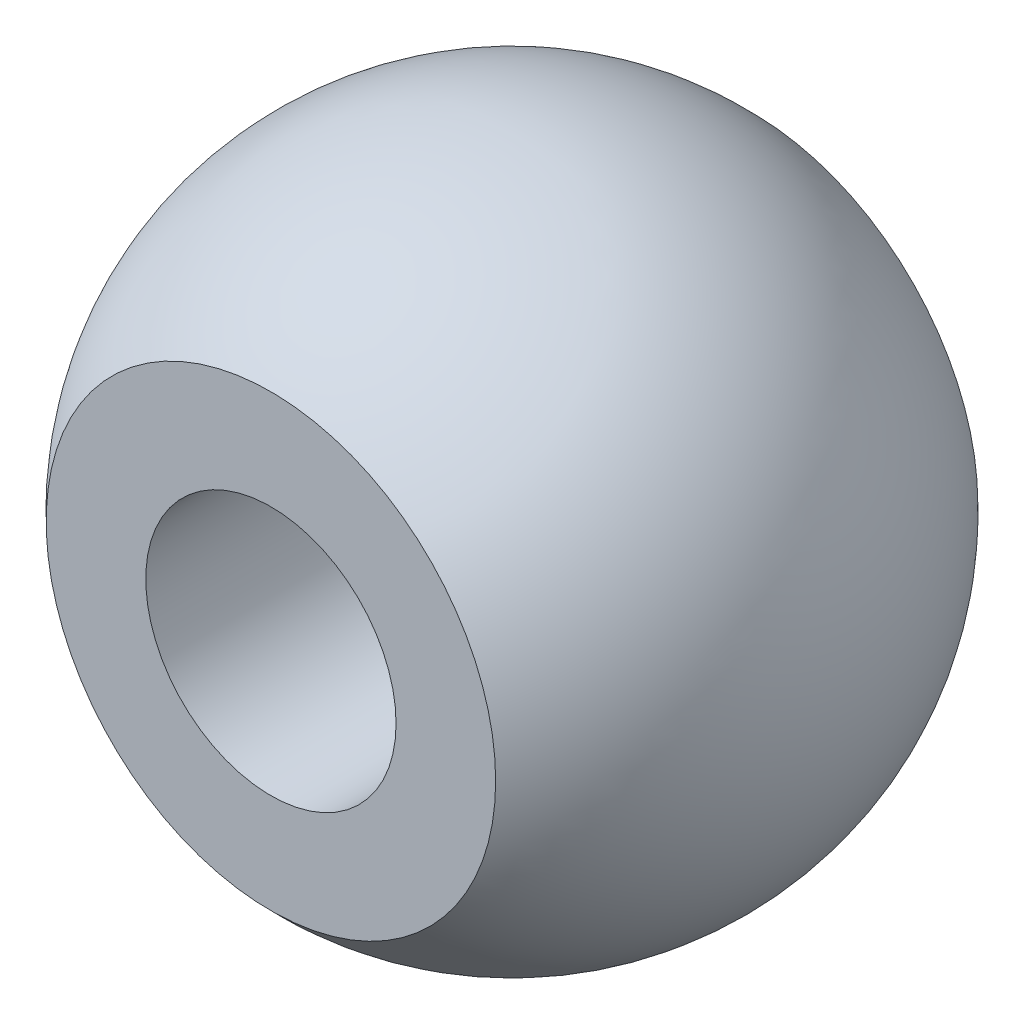
from build123d import *

# Parameters (mm, degrees)
CUT_EXTRUDE1_DEPTH      = 7.84160069
CUT_EXTRUDE1_DEPTH_BACK = 7.84160069
SKETCH2_W               = 7.9
SKETCH2_H               = 1.060956176
SKETCH3_R               = 1.5
CUT_EXTRUDE2_DEPTH      = 9.036871086


with BuildPart() as part:
    # Sketch1 → Revolve4 (revolve)
    with BuildSketch(Plane(origin=(0, 0, 0), x_dir=(1, 0, 0), z_dir=(0, 1, 0))):
        with BuildLine():
            Line((0, -3.95), (0, 3.95))
            ThreePointArc((0, 3.95), (3.95, 0), (0, -3.95))
        make_face()
    revolve(axis=Axis((0, 0, 3.95), (0, 0, -1)))

    # Sketch2 → Cut-Extrude1 (cut, two sides: drawn at the far end of the back side and taken through both)
    with BuildSketch(Plane(origin=(0, 0, 0), x_dir=(1, 0, 0), z_dir=(0, 1, 0)).offset(-CUT_EXTRUDE1_DEPTH_BACK)):
        with Locations((0, -3.419521912)):
            Rectangle(SKETCH2_W, SKETCH2_H)
        with Locations((0, 3.419521912)):
            Rectangle(SKETCH2_W, SKETCH2_H)
    extrude(amount=CUT_EXTRUDE1_DEPTH + CUT_EXTRUDE1_DEPTH_BACK, mode=Mode.SUBTRACT)

    # Sketch3 → Cut-Extrude2 (cut, through all)
    with BuildSketch(Plane.XY.offset(2.889043824)):
        Circle(SKETCH3_R)
    extrude(amount=-CUT_EXTRUDE2_DEPTH, mode=Mode.SUBTRACT)


solid = part.part
